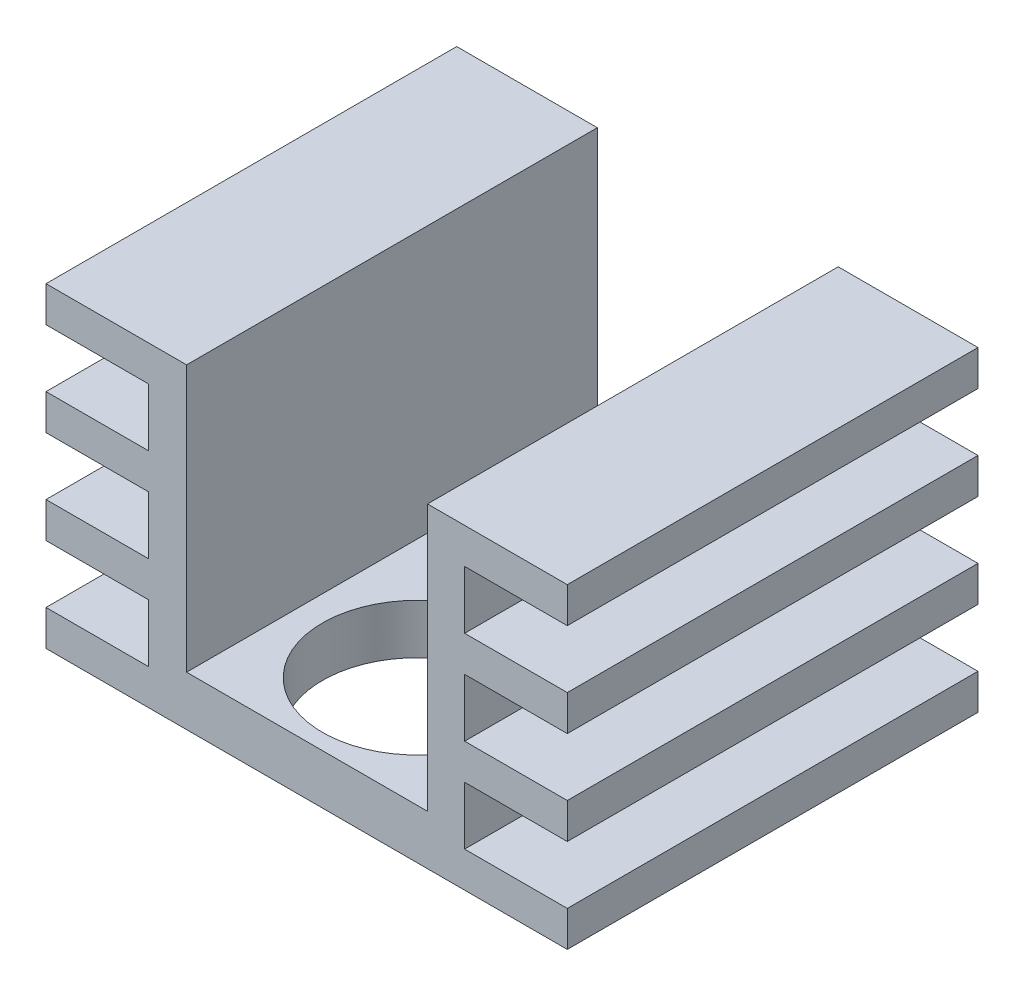
from build123d import *

# Parameters (mm, degrees)
SKETCH1_W           = 33
SKETCH1_H           = 26
SKETCH1_R           = 6
BOSS_EXTRUDE1_DEPTH = 20
SKETCH2_W           = 6.5
SKETCH2_H           = 3.666666667
SKETCH2_H_2         = 3.666666666
SKETCH2_W_2         = 15.25
SKETCH2_H_3         = 16.85
CUT_EXTRUDE1_DEPTH  = 26


with BuildPart() as part:
    # Sketch1 → Boss-Extrude1 (new body)
    with BuildSketch(Plane(origin=(0, 0, 0), x_dir=(1, 0, 0), z_dir=(0, 1, 0))):
        with Locations((16.5, 13)):
            Rectangle(SKETCH1_W, SKETCH1_H)
        with Locations((16.5, 7)):
            Circle(SKETCH1_R, mode=Mode.SUBTRACT)
    extrude(amount=BOSS_EXTRUDE1_DEPTH)

    # Sketch2 → Cut-Extrude1 (cut)
    with BuildSketch(Plane.XY):
        with Locations((3.25, 4.083333334)):
            Rectangle(SKETCH2_W, SKETCH2_H)
        with Locations((3.25, 10)):
            Rectangle(SKETCH2_W, SKETCH2_H_2)
        with Locations((3.25, 15.916666666)):
            Rectangle(SKETCH2_W, SKETCH2_H)
        with Locations((29.75, 15.916666666)):
            Rectangle(SKETCH2_W, SKETCH2_H)
        with Locations((29.75, 10)):
            Rectangle(SKETCH2_W, SKETCH2_H_2)
        with Locations((29.75, 4.083333334)):
            Rectangle(SKETCH2_W, SKETCH2_H)
        with Locations((16.525, 11.575)):
            Rectangle(SKETCH2_W_2, SKETCH2_H_3)
    extrude(amount=-CUT_EXTRUDE1_DEPTH, mode=Mode.SUBTRACT)


solid = part.part
